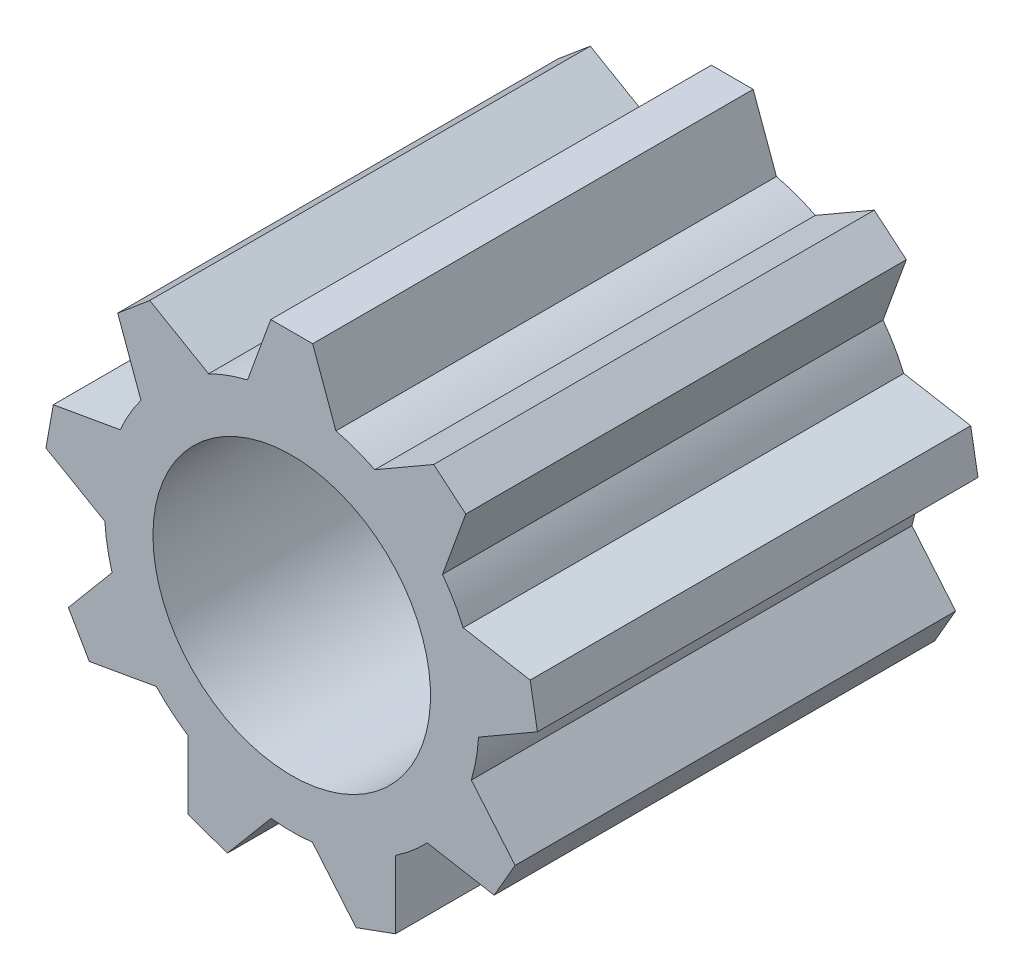
from build123d import *

# Parameters (mm, degrees)
SKETCH1_R         = 4.25
EXTRUDE1_DEPTH    = 10
SKETCH3_R         = 3.15
EXTRUDE2_DEPTH    = 11
EXTRUDE3_DEPTH    = 10
CIRPATTERN1_COUNT = 9


with BuildPart() as part:
    # Sketch1 → Extrude1 (new body)
    with BuildSketch(Plane.XY):
        Circle(SKETCH1_R)
    extrude(amount=EXTRUDE1_DEPTH)

    # Sketch3 → Extrude2 (cut, through all)
    with BuildSketch(Plane(origin=(0, 0, 0), x_dir=(-1, 0, 0), z_dir=(0, 0, -1))):
        Circle(SKETCH3_R)
    extrude(amount=-EXTRUDE2_DEPTH, mode=Mode.SUBTRACT)

    # Sketch4 → Extrude3 (add)
    with BuildSketch(Plane.XY):
        Polygon((-0.475, 5.58000953), (0.475, 5.58000953), (1.00275684, 4.13000953), (-1.00275684, 4.13000953), align=None)
    extrude3 = extrude(amount=EXTRUDE3_DEPTH)

    # CirPattern1: Extrude3 ×9 about axis
    cirpattern1_axis = Axis((0, 0, 0), (0, 0, 1))
    for i in range(1, CIRPATTERN1_COUNT):
        add(extrude3.rotate(cirpattern1_axis, i * 360 / CIRPATTERN1_COUNT))


solid = part.part
